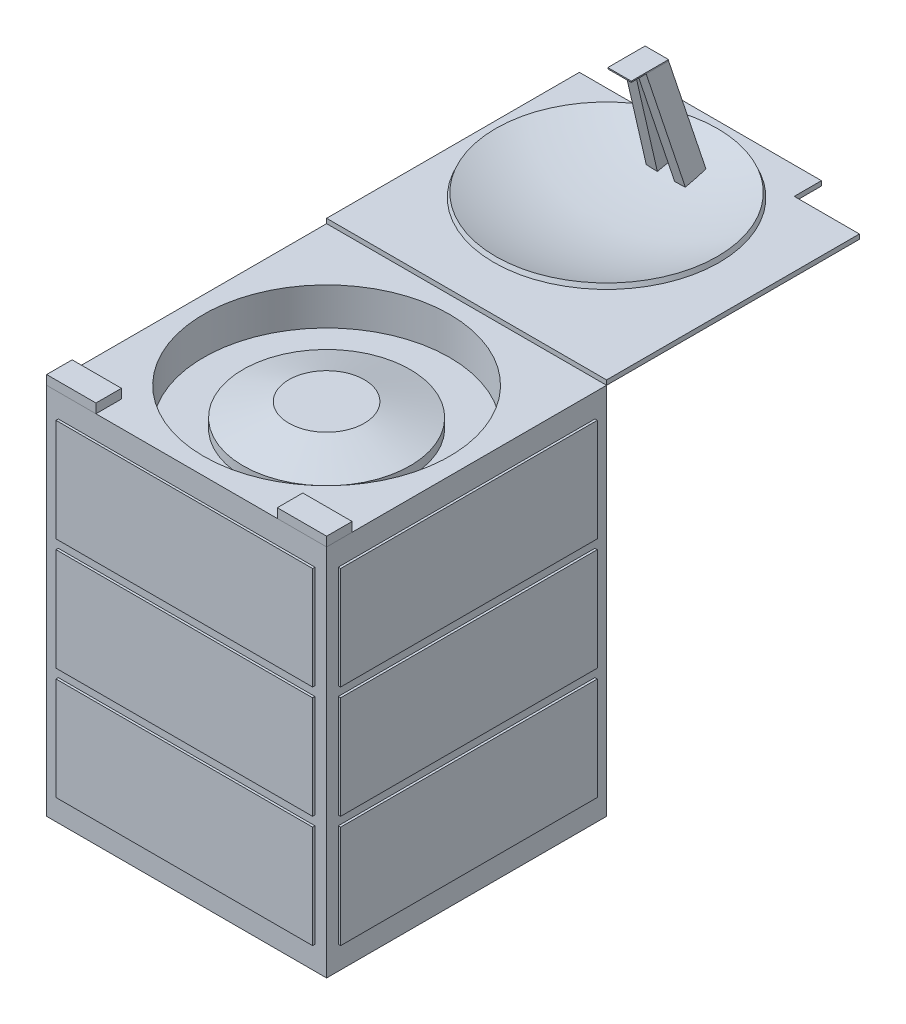
from build123d import *

# Parameters (mm, degrees)
SKETCH1_W               = 600
SKETCH1_H               = 600
BOSS_EXTRUDE1_DEPTH     = 800
SKETCH2_R               = 263.572920461
CUT_EXTRUDE2_DEPTH      = 80
SKETCH3_R               = 178.989072731
BOSS_EXTRUDE2_DEPTH     = 50
CHAMFER1_SIZE           = 30
CHAMFER1_SIZE2          = 98.125578555
SKETCH4_W               = 600
SKETCH4_H               = 600
BOSS_EXTRUDE3_DEPTH     = 10
SKETCH5_W               = 139.574184058
SKETCH5_H               = 58.278087479
CUT_EXTRUDE3_DEPTH      = 1
CUT_EXTRUDE3_DEPTH_BACK = 811
SKETCH8_W               = 23.493361295
SKETCH8_H               = 48.054602649
SKETCH9_W               = 23.493361295
SKETCH9_H               = 48.054602649
SKETCH8_7_W             = 23.493361295
SKETCH8_7_H             = 48.054602649
SKETCH9_4_W             = 23.493361295
SKETCH9_4_H             = 48.054602649
SKETCH11_W              = 50.336707402
SKETCH11_H              = 80
BOSS_EXTRUDE4_DEPTH     = 2.5
SKETCH12_W              = 550
SKETCH12_H              = 220
BOSS_EXTRUDE5_DEPTH     = 5
SKETCH13_W              = 550
SKETCH13_H              = 220
BOSS_EXTRUDE6_DEPTH     = 5
SKETCH14_W              = 105.681406042
SKETCH14_H              = 54.65067211
BOSS_EXTRUDE7_DEPTH     = 20
BOSS_EXTRUDE7_2_DEPTH   = 20


with BuildPart() as part:
    # Sketch1 → Boss-Extrude1 (new body)
    with BuildSketch(Plane(origin=(0, 0, 0), x_dir=(1, 0, 0), z_dir=(0, 1, 0))):
        Rectangle(SKETCH1_W, SKETCH1_H)
    extrude(amount=BOSS_EXTRUDE1_DEPTH)

    # Sketch2 → Cut-Extrude2 (cut)
    with BuildSketch(Plane(origin=(0, 800, 0), x_dir=(1, 0, 0), z_dir=(0, 1, 0))):
        Circle(SKETCH2_R)
    extrude(amount=-CUT_EXTRUDE2_DEPTH, mode=Mode.SUBTRACT)

    # Sketch3 → Boss-Extrude2 (add)
    with BuildSketch(Plane(origin=(0, 720, 0), x_dir=(1, 0, 0), z_dir=(0, 1, 0))):
        Circle(SKETCH3_R)
    extrude(amount=BOSS_EXTRUDE2_DEPTH)

    # Chamfer1
    chamfer1_edges = [part.edges().sort_by_distance(p)[0] for p in [
        (-178.989072731, 770, 0),
    ]]
    chamfer1_side = [part.faces().sort_by_distance(p)[0] for p in [
        (-178.989072731, 745, 0),
    ]]
    chamfer(chamfer1_edges, length=CHAMFER1_SIZE, length2=CHAMFER1_SIZE2, reference=chamfer1_side[0])

    # Sketch12 → Boss-Extrude5 (add)
    with BuildSketch(Plane.ZY.offset(300)):
        with Locations((0, 640)):
            Rectangle(SKETCH12_W, SKETCH12_H)
        with Locations((0, 400)):
            Rectangle(SKETCH12_W, SKETCH12_H)
        with Locations((0, 160)):
            Rectangle(SKETCH12_W, SKETCH12_H)
    boss_extrude5 = extrude(amount=BOSS_EXTRUDE5_DEPTH)

    # Mirror1: Boss-Extrude5 across plane
    add(boss_extrude5.mirror(Plane(origin=(0, 0, 0), x_dir=(0, 0, 1), z_dir=(1, 0, 0))))

    # Sketch13 → Boss-Extrude6 (add)
    with BuildSketch(Plane.XY.offset(300)):
        with Locations((0, 640)):
            Rectangle(SKETCH13_W, SKETCH13_H)
        with Locations((0, 400)):
            Rectangle(SKETCH13_W, SKETCH13_H)
        with Locations((0, 160)):
            Rectangle(SKETCH13_W, SKETCH13_H)
    boss_extrude6 = extrude(amount=BOSS_EXTRUDE6_DEPTH)

    # Mirror2: Boss-Extrude6 across plane
    add(boss_extrude6.mirror(Plane.XY))


with BuildPart() as body_2:
    # Sketch4 → Boss-Extrude3 (new body)
    with BuildSketch(Plane(origin=(0, 800, 0), x_dir=(1, 0, 0), z_dir=(0, 1, 0))):
        with Locations((0, 600)):
            Rectangle(SKETCH4_W, SKETCH4_H)
    extrude(amount=BOSS_EXTRUDE3_DEPTH)

    # Sketch5 → Cut-Extrude3 (cut, two sides)
    with BuildSketch(Plane(origin=(0, 810, 0), x_dir=(1, 0, 0), z_dir=(0, 1, 0))) as cut_extrude3_sk:
        with Locations((230.212907971, 870.86095626)):
            Rectangle(SKETCH5_W, SKETCH5_H)
        with Locations((-230.212907971, 870.86095626)):
            Rectangle(SKETCH5_W, SKETCH5_H)
    extrude(amount=CUT_EXTRUDE3_DEPTH, mode=Mode.SUBTRACT)
    extrude(cut_extrude3_sk.sketch, amount=-CUT_EXTRUDE3_DEPTH_BACK, mode=Mode.SUBTRACT)

    # Sketch8 → Loft2 section 0
    with BuildSketch(Plane(origin=(0, 810, 0), x_dir=(1, 0, 0), z_dir=(0, 1, 0))):
        with Locations((31.210643238, 755.294036312)):
            Rectangle(SKETCH8_W, SKETCH8_H)
    # Sketch9 → Loft2 section 1
    with BuildSketch(Plane(origin=(0, 1060, 0), x_dir=(1, 0, 0), z_dir=(0, 1, 0))):
        with Locations((12.644197915, 684.450320998)):
            Rectangle(SKETCH9_W, SKETCH9_H)
    loft()

    # Sketch8_7 → Loft3 section 0
    with BuildSketch(Plane(origin=(0, 810, 0), x_dir=(1, 0, 0), z_dir=(0, 1, 0))):
        with Locations((-31.210643238, 755.294036312)):
            Rectangle(SKETCH8_7_W, SKETCH8_7_H)
    # Sketch9_4 → Loft3 section 1
    with BuildSketch(Plane(origin=(0, 1060, 0), x_dir=(1, 0, 0), z_dir=(0, 1, 0))):
        with Locations((-14.199148193, 684.622952273)):
            Rectangle(SKETCH9_4_W, SKETCH9_4_H)
    loft()

    # Sketch10 → Cut-Revolve1 (revolve, cut)
    with BuildSketch(Plane(origin=(0, 0, 0), x_dir=(0, 0, -1), z_dir=(1, 0, 0))):
        Polygon((720.934851244, 810), (787.561546381, 810), (784.086687345, 827.772629133), (720.934851244, 811.831453048), align=None)
    revolve(axis=Axis((0, 533.301130193, -600), (0, 1, 0)), mode=Mode.SUBTRACT)


with BuildPart() as body_3:
    # Sketch7 → Revolve-Thin1 (revolve)
    with BuildSketch(Plane(origin=(0, 0, 0), x_dir=(0, 0, -1), z_dir=(1, 0, 0))):
        with BuildLine():
            ThreePointArc((600, 810), (721.180877874, 822.077451842), (837.594329941, 857.834663464))
            Line((837.594329941, 857.834663464), (841.464059464, 848.613752803))
            ThreePointArc((841.464059464, 848.613752803), (723.154566475, 812.27415886), (600, 800))
            Line((600, 800), (600, 810))
        make_face()
    revolve(axis=Axis((0, 533.301130193, -600), (0, 1, 0)))


with BuildPart() as body_4:
    # Sketch11 → Boss-Extrude4 (new body)
    with BuildSketch(Plane(origin=(0, 1060, 0), x_dir=(1, 0, 0), z_dir=(0, 1, 0))):
        with Locations((-0.777475139, 668.477622322)):
            Rectangle(SKETCH11_W, SKETCH11_H)
    extrude(amount=BOSS_EXTRUDE4_DEPTH)


with BuildPart() as body_5:
    # Sketch14 → Boss-Extrude7 (new body)
    with BuildSketch(Plane(origin=(0, 800, 0), x_dir=(1, 0, 0), z_dir=(0, 1, 0))):
        with Locations((247.159296979, -272.674663945)):
            Rectangle(SKETCH14_W, SKETCH14_H)
    extrude(amount=BOSS_EXTRUDE7_DEPTH)


with BuildPart() as body_6:
    # Sketch14 → Boss-Extrude7 2 (new body)
    with BuildSketch(Plane(origin=(0, 800, 0), x_dir=(1, 0, 0), z_dir=(0, 1, 0))):
        with Locations((-247.159296979, -272.674663945)):
            Rectangle(SKETCH14_W, SKETCH14_H)
    extrude(amount=BOSS_EXTRUDE7_2_DEPTH)


solid = Compound([part.part, body_2.part, body_3.part, body_4.part, body_5.part, body_6.part])
